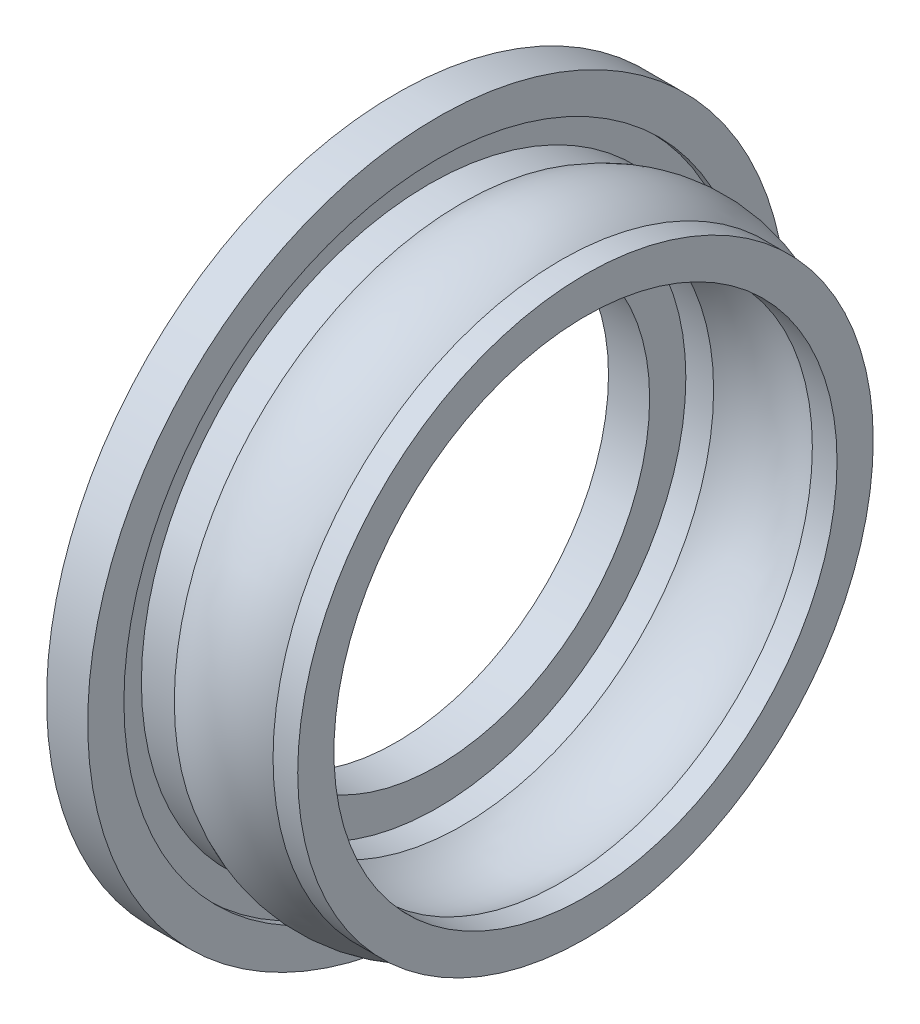
from build123d import *

# Parameters (mm, degrees)
SKETCH1_R           = 17
SKETCH1_R_2         = 10.32
BOSS_EXTRUDE1_DEPTH = 2
SKETCH5_R           = 15.24
SKETCH5_R_2         = 13.99
CUT_EXTRUDE1_DEPTH  = 0.4
SKETCH6_R           = 12.23
SKETCH6_R_2         = 12.08
CUT_EXTRUDE2_DEPTH  = 0.4


with BuildPart() as part:
    # Sketch1 → Boss-Extrude1 (new body)
    with BuildSketch(Plane(origin=(0, 0, 0), x_dir=(0, 0, -1), z_dir=(1, 0, 0))):
        Circle(SKETCH1_R)
        Circle(SKETCH1_R_2, mode=Mode.SUBTRACT)
    extrude(amount=BOSS_EXTRUDE1_DEPTH)

    # Sketch4 → Revolve3 (revolve)
    with BuildSketch(Plane(origin=(0, 0, 0), x_dir=(1, 0, 0), z_dir=(0, 1, 0))):
        with BuildLine():
            Line((9.2, 13.99), (9.2, 12.23))
            Line((9.2, 12.23), (8, 12.23))
            ThreePointArc((8, 12.23), (5.6, 12.89), (3.2, 12.23))
            Line((3.2, 12.23), (2, 12.23))
            Line((2, 12.23), (2, 13.99))
            Line((2, 13.99), (3.199999942, 13.99))
            ThreePointArc((3.199999942, 13.99), (5.599998351, 14.65), (7.999996761, 13.99))
            Line((7.999996761, 13.99), (9.2, 13.99))
        make_face()
    revolve(axis=Axis((2, 0, 0), (-1, 0, 0)))

    # Sketch5 → Cut-Extrude1 (cut)
    with BuildSketch(Plane(origin=(2, 0, 0), x_dir=(0, 0, -1), z_dir=(1, 0, 0))):
        Circle(SKETCH5_R)
        Circle(SKETCH5_R_2, mode=Mode.SUBTRACT)
    extrude(amount=-CUT_EXTRUDE1_DEPTH, mode=Mode.SUBTRACT)

    # Sketch6 → Cut-Extrude2 (cut)
    with BuildSketch(Plane(origin=(2, 0, 0), x_dir=(0, 0, -1), z_dir=(1, 0, 0))):
        Circle(SKETCH6_R)
        Circle(SKETCH6_R_2, mode=Mode.SUBTRACT)
    extrude(amount=-CUT_EXTRUDE2_DEPTH, mode=Mode.SUBTRACT)


solid = part.part
